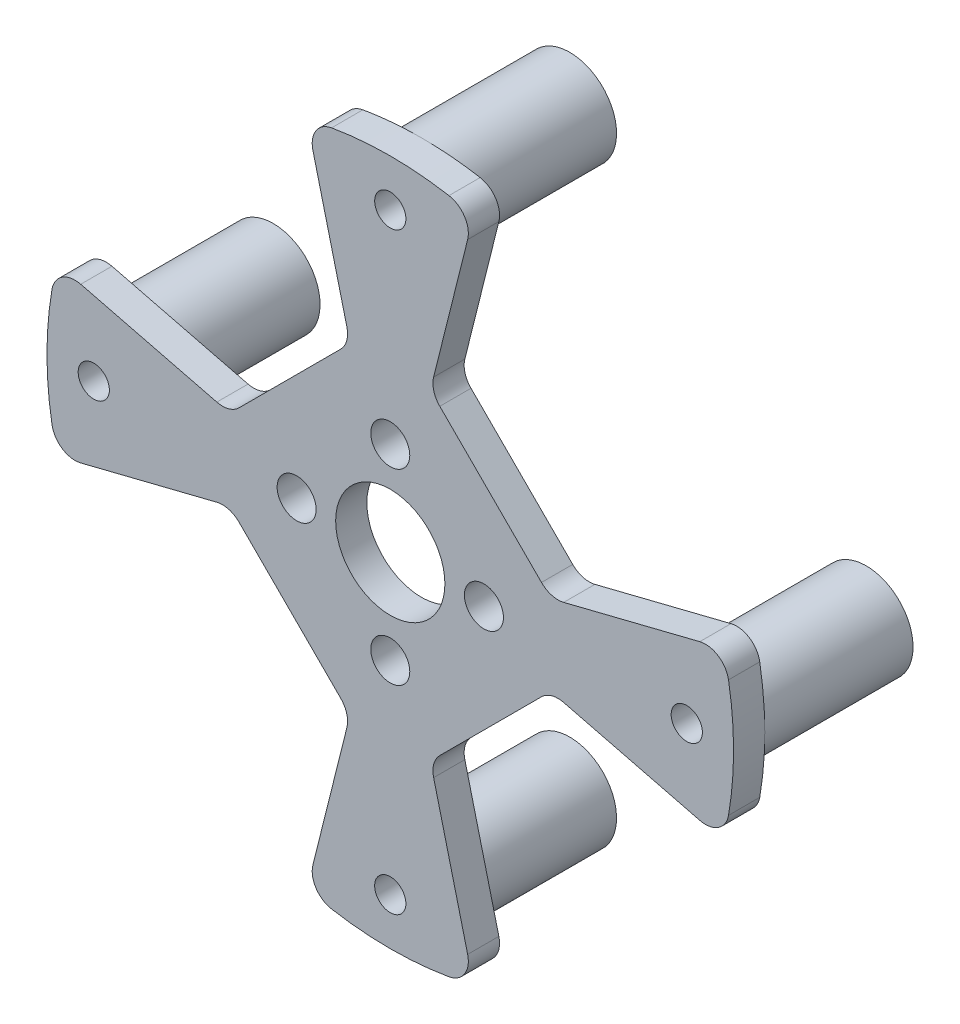
from build123d import *

# Parameters (mm, degrees)
SKETCH_1_R               = 22
EXTRUDE_1_DEPTH          = 2
SKETCH_3_R               = 1.25
CUT_EXTRUDE_1_DEPTH      = 3
SKETCH_4_R               = 3.5
CUT_EXTRUDE_2_DEPTH      = 3
SKETCH_6_R               = 3
EXTRUDE_3_DEPTH          = 9.5
SKETCH_8_R               = 1
CUT_EXTRUDE_4_DEPTH      = 11.5
CUT_EXTRUDE_3_DEPTH      = 6
PATTERN_CIRCULAR_1_COUNT = 4
FILLET_2_R               = 1.5
FILLET_3_R               = 1.5


with BuildPart() as part:
    # 草图1 → 凸台-拉伸1 (new body)
    with BuildSketch(Plane.XY):
        Circle(SKETCH_1_R)
    extrude(amount=EXTRUDE_1_DEPTH)

    # 草图3 → 切除-拉伸1 (cut)
    with BuildSketch(Plane(origin=(0, 0, 0), x_dir=(-1, 0, 0), z_dir=(0, 0, -1))):
        with Locations((6, 0)):
            Circle(SKETCH_3_R)
    cut_extrude_1 = extrude(amount=-CUT_EXTRUDE_1_DEPTH, mode=Mode.SUBTRACT)

    # 草图4 → 切除-拉伸2 (cut)
    with BuildSketch(Plane(origin=(0, 0, 0), x_dir=(-1, 0, 0), z_dir=(0, 0, -1))):
        Circle(SKETCH_4_R)
    extrude(amount=-CUT_EXTRUDE_2_DEPTH, mode=Mode.SUBTRACT)

    # 草图6 → 凸台-拉伸3 (add)
    with BuildSketch(Plane(origin=(0, 0, 0), x_dir=(-1, 0, 0), z_dir=(0, 0, -1))):
        with Locations((0, -19)):
            Circle(SKETCH_6_R)
    extrude_3 = extrude(amount=EXTRUDE_3_DEPTH)

    # 草图8 → 切除-拉伸4 (cut)
    with BuildSketch(Plane(origin=(0, 0, -9.5), x_dir=(-1, 0, 0), z_dir=(0, 0, -1))):
        with Locations((0, -19)):
            Circle(SKETCH_8_R)
    cut_extrude_4 = extrude(amount=-CUT_EXTRUDE_4_DEPTH, mode=Mode.SUBTRACT)

    # 草图7 → 切除-拉伸3 (cut)
    with BuildSketch(Plane(origin=(0, 0, 0), x_dir=(-1, 0, 0), z_dir=(0, 0, -1))):
        Polygon((-2.572740594, 10.290962376), (-10.290962376, 2.572740594), (-30.512752563, 7.628188141), (-7.628188141, 30.512752563), align=None)
    cut_extrude_3 = extrude(amount=-CUT_EXTRUDE_3_DEPTH, mode=Mode.SUBTRACT)

    # 阵列(圆周)1: 切除-拉伸1, 凸台-拉伸3, 切除-拉伸4, 切除-拉伸3 ×4 about axis
    pattern_circular_1_axis = Axis((0, 0, 0), (0, 0, 1))
    for i in range(1, PATTERN_CIRCULAR_1_COUNT):
        add(cut_extrude_1.rotate(pattern_circular_1_axis, i * 360 / PATTERN_CIRCULAR_1_COUNT), mode=Mode.SUBTRACT)
        add(extrude_3.rotate(pattern_circular_1_axis, i * 360 / PATTERN_CIRCULAR_1_COUNT))
        add(cut_extrude_4.rotate(pattern_circular_1_axis, i * 360 / PATTERN_CIRCULAR_1_COUNT), mode=Mode.SUBTRACT)
        add(cut_extrude_3.rotate(pattern_circular_1_axis, i * 360 / PATTERN_CIRCULAR_1_COUNT), mode=Mode.SUBTRACT)

    # 圆角2
    fillet_2_edges = [part.edges().sort_by_distance(p)[0] for p in [
        (-5.335783751, -21.343135003, 1),
        (-21.343135003, -5.335783751, 1),
        (21.343135003, -5.335783751, 1),
        (5.335783751, -21.343135003, 1),
        (5.335783751, 21.343135003, 1),
        (21.343135003, 5.335783751, 1),
        (-21.343135003, 5.335783751, 1),
        (-5.335783751, 21.343135003, 1),
    ]]
    fillet(fillet_2_edges, radius=FILLET_2_R)

    # 圆角3
    fillet_3_edges = [part.edges().sort_by_distance(p)[0] for p in [
        (-10.290962376, -2.572740594, 1),
        (-2.572740594, -10.290962376, 1),
        (2.572740594, -10.290962376, 1),
        (10.290962376, -2.572740594, 1),
        (10.290962376, 2.572740594, 1),
        (2.572740594, 10.290962376, 1),
        (-2.572740594, 10.290962376, 1),
        (-10.290962376, 2.572740594, 1),
    ]]
    fillet(fillet_3_edges, radius=FILLET_3_R)


solid = part.part
